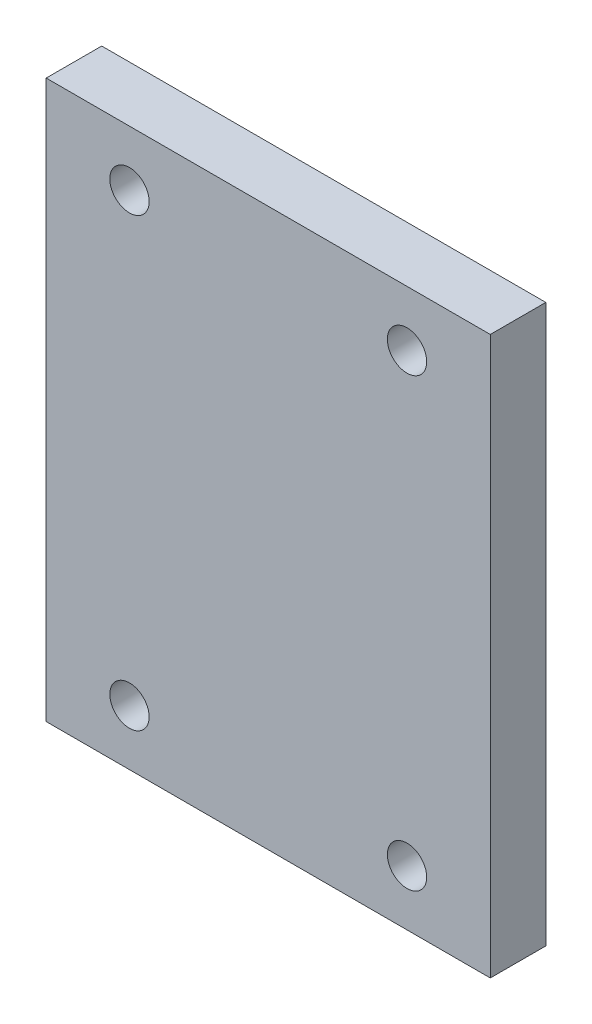
from build123d import *

# Parameters (mm, degrees)
SKETCH1_W            = 50.8
SKETCH1_H            = 63.754
BOSS_EXTRUDE1_DEPTH  = 6.35
M4_CLEARANCE_HOLE1_D = 4.5


with BuildPart() as part:
    # Sketch1 → Boss-Extrude1 (new body)
    with BuildSketch(Plane.XY):
        Rectangle(SKETCH1_W, SKETCH1_H)
    extrude(amount=BOSS_EXTRUDE1_DEPTH)

    # M4 Clearance Hole1 (through all)
    with Locations(Plane(origin=(0, 0, 0), x_dir=(-1, 0, 0), z_dir=(0, 0, -1))):
        with Locations((-15.875, 25.527), (15.875, 25.527), (15.875, -25.527), (-15.875, -25.527)):
            Hole(M4_CLEARANCE_HOLE1_D / 2)


solid = part.part
